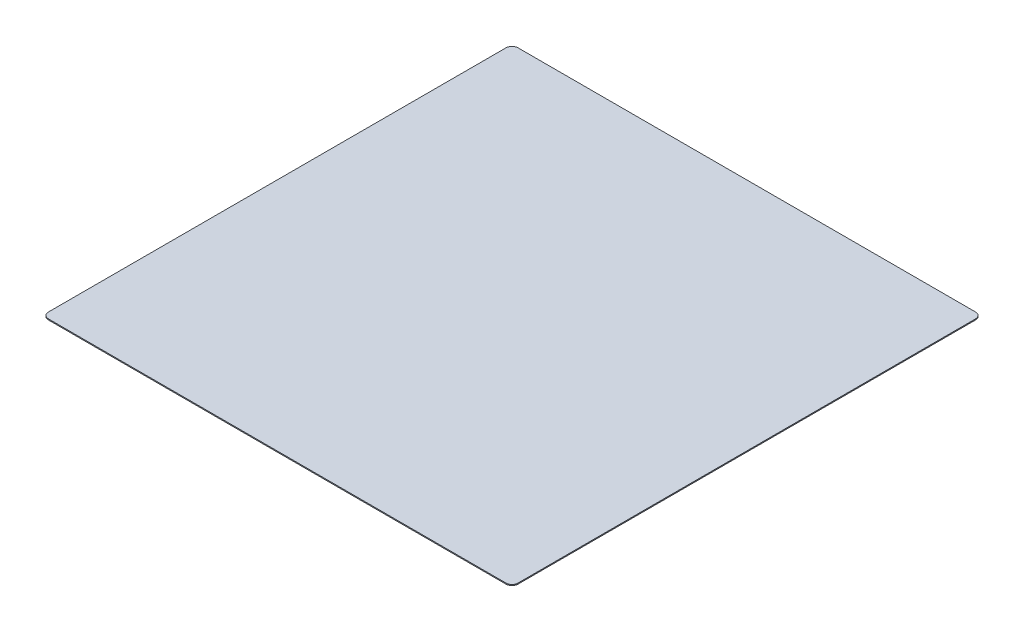
from build123d import *

# Parameters (mm, degrees)
AUFSATZ_LINEAR_AUSTRAGEN1_DEPTH = 0.5


with BuildPart() as part:
    # Skizze1 → Aufsatz-Linear austragen1 (new body)
    with BuildSketch(Plane(origin=(0, 0, 0), x_dir=(1, 0, 0), z_dir=(0, 1, 0))):
        with BuildLine():
            Line((-114.5, -117.5), (114.5, -117.5))
            ThreePointArc((114.5, -117.5), (116.621320344, -116.621320344), (117.5, -114.5))
            Line((117.5, -114.5), (117.5, 114.5))
            ThreePointArc((117.5, 114.5), (116.621320344, 116.621320344), (114.5, 117.5))
            Line((114.5, 117.5), (-114.5, 117.5))
            ThreePointArc((-114.5, 117.5), (-116.621320344, 116.621320344), (-117.5, 114.5))
            Line((-117.5, 114.5), (-117.5, -114.5))
            ThreePointArc((-117.5, -114.5), (-116.621320344, -116.621320344), (-114.5, -117.5))
        make_face()
    extrude(amount=AUFSATZ_LINEAR_AUSTRAGEN1_DEPTH)


solid = part.part
